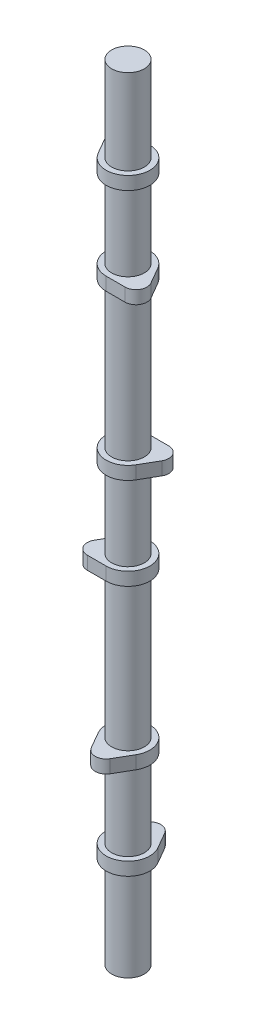
from build123d import *

# Parameters (mm, degrees)
BOSS_EXTRUDE1_DEPTH   = 7.62
LPATTERN3_COUNT       = 2
LPATTERN3_PITCH       = 53.34
BODY_MOVE_COPY1_ANGLE = 180
LPATTERN5_COUNT       = 3
LPATTERN5_PITCH       = 146.05
BODY_MOVE_COPY2_ANGLE = 120
BODY_MOVE_COPY3_ANGLE = 120
BOSS_EXTRUDE2_START   = 49.53
SKETCH3_R             = 9.5
BOSS_EXTRUDE2_DEPTH   = 456.09


with BuildPart() as part:
    # Sketch2 → Boss-Extrude1 (new body)
    with BuildSketch(Plane(origin=(0, 0, 0), x_dir=(1, 0, 0), z_dir=(0, 1, 0))):
        with BuildLine():
            Line((-10.998522628, 6.35), (-5.499261314, 15.875))
            ThreePointArc((-5.499261314, 15.875), (0, 19.05), (5.499261314, 15.875))
            Line((5.499261314, 15.875), (10.998522628, 6.35))
            ThreePointArc((10.998522628, 6.35), (0, -12.7), (-10.998522628, 6.35))
        make_face()
    extrude(amount=BOSS_EXTRUDE1_DEPTH)


with BuildPart() as lpattern3_1:
    # LPattern3: pattern copy
    add(part.part.moved(Location(Vector(0, 1, 0) * (1 * LPATTERN3_PITCH))))


with BuildPart() as lpattern3_1_1:
    # Body-Move_Copy1: moved
    add(lpattern3_1.part.rotate(Axis((0, 0, 0), (0, 1, 0)), BODY_MOVE_COPY1_ANGLE))


with BuildPart() as lpattern5_1:
    # LPattern5: pattern copy
    add(lpattern3_1_1.part.moved(Location(Vector(0, 1, 0) * (1 * LPATTERN5_PITCH))))


with BuildPart() as lpattern5_2:
    # LPattern5: pattern copy
    add(lpattern3_1_1.part.moved(Location(Vector(0, 1, 0) * (2 * LPATTERN5_PITCH))))


with BuildPart() as lpattern5_3:
    # LPattern5: pattern copy
    add(part.part.moved(Location(Vector(0, 1, 0) * (1 * LPATTERN5_PITCH))))


with BuildPart() as lpattern5_4:
    # LPattern5: pattern copy
    add(part.part.moved(Location(Vector(0, 1, 0) * (2 * LPATTERN5_PITCH))))


with BuildPart() as lpattern5_3_1:
    # Body-Move_Copy2: moved
    add(lpattern5_3.part.rotate(Axis((0, 0, 0), (0, 1, 0)), BODY_MOVE_COPY2_ANGLE))


with BuildPart() as lpattern5_1_1:
    # Body-Move_Copy2: moved
    add(lpattern5_1.part.rotate(Axis((0, 0, 0), (0, 1, 0)), BODY_MOVE_COPY2_ANGLE))


with BuildPart() as lpattern5_4_1:
    # Body-Move_Copy3: moved
    add(lpattern5_4.part.rotate(Axis((0, 0, 0), (0, -1, 0)), BODY_MOVE_COPY3_ANGLE))


with BuildPart() as lpattern5_2_1:
    # Body-Move_Copy3: moved
    add(lpattern5_2.part.rotate(Axis((0, 0, 0), (0, -1, 0)), BODY_MOVE_COPY3_ANGLE))

    # Sketch3 → Boss-Extrude2 (add)
    with BuildSketch(Plane(origin=(0, 353.06, 0), x_dir=(1, 0, 0), z_dir=(0, 1, 0)).offset(BOSS_EXTRUDE2_START)):
        Circle(SKETCH3_R)
    extrude(amount=-BOSS_EXTRUDE2_DEPTH)


solid = Compound([part.part, lpattern3_1_1.part, lpattern5_3_1.part, lpattern5_1_1.part, lpattern5_4_1.part, lpattern5_2_1.part])
